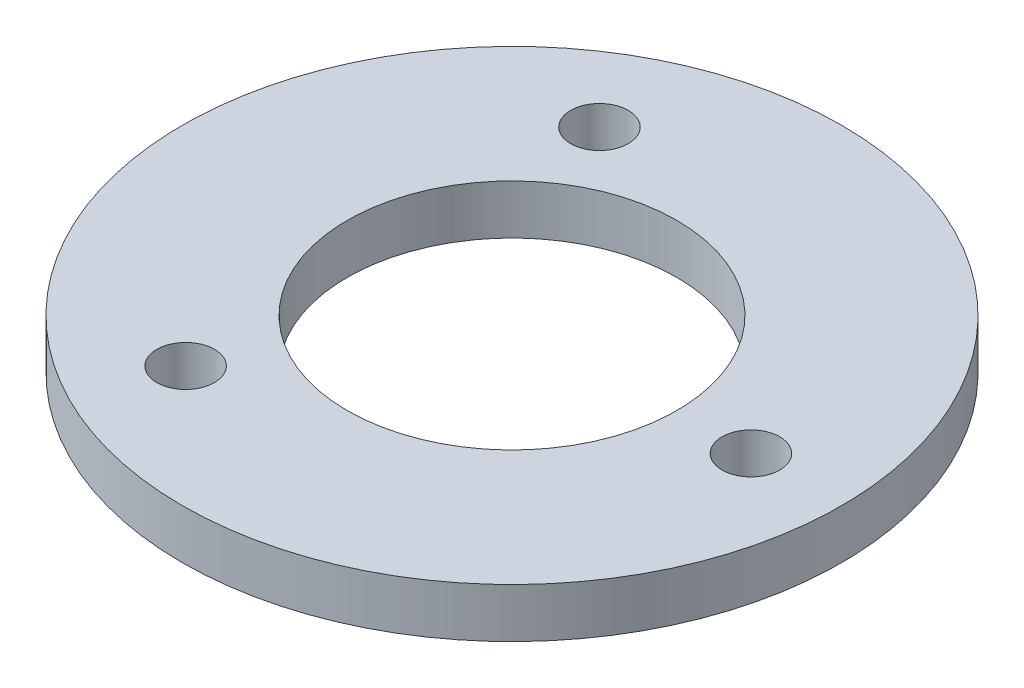
from build123d import *

# Parameters (mm, degrees)
SKETCH1_R           = 20
SKETCH1_R_2         = 10
SKETCH1_R_3         = 1.75
BOSS_EXTRUDE1_DEPTH = 3


with BuildPart() as part:
    # Sketch1 → Boss-Extrude1 (new body)
    with BuildSketch(Plane(origin=(0, 0, 0), x_dir=(1, 0, 0), z_dir=(0, 1, 0))):
        Circle(SKETCH1_R)
        Circle(SKETCH1_R_2, mode=Mode.SUBTRACT)
        with Locations((14.5, 0)):
            Circle(SKETCH1_R_3, mode=Mode.SUBTRACT)
        with Locations((-7.25, -12.557368355)):
            Circle(SKETCH1_R_3, mode=Mode.SUBTRACT)
        with Locations((-7.25, 12.557368355)):
            Circle(SKETCH1_R_3, mode=Mode.SUBTRACT)
    extrude(amount=BOSS_EXTRUDE1_DEPTH)


solid = part.part
